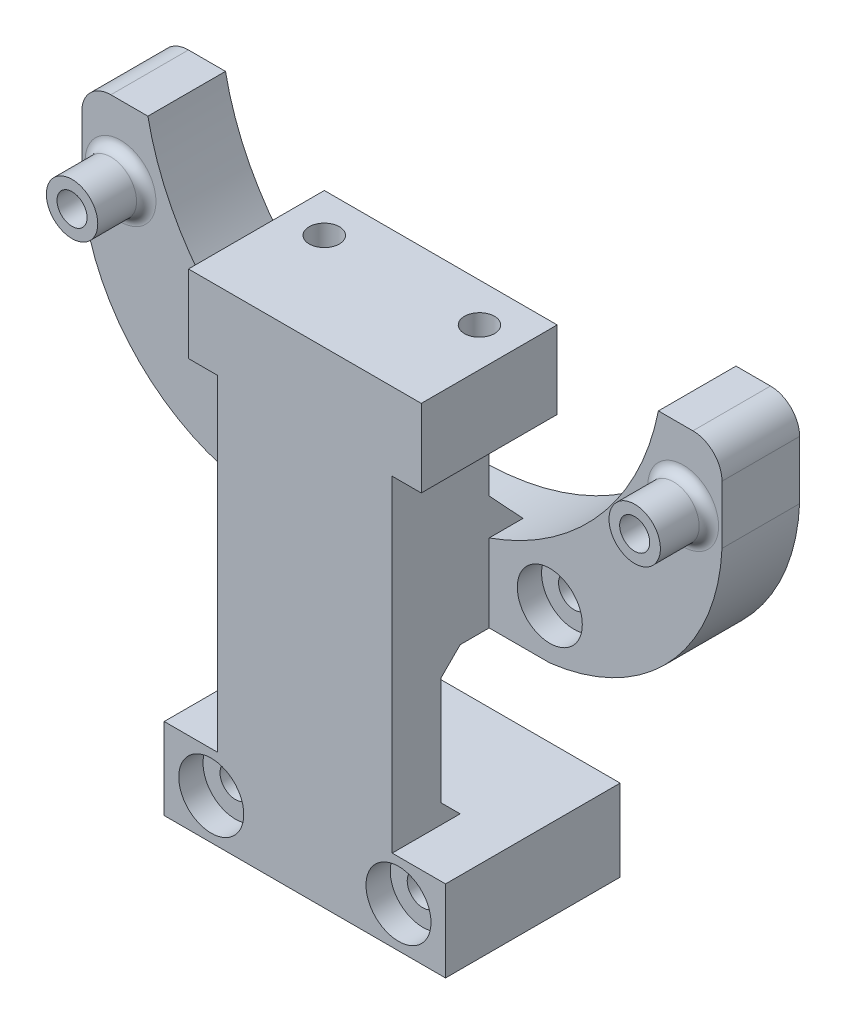
from build123d import *

# Parameters (mm, degrees)
SKETCH_1_R          = 1.6
SKETCH_1_R_2        = 1.55
EXTRUDE_1_DEPTH     = 8
SKETCH_2_R          = 1.6
EXTRUDE_2_DEPTH     = 10
SKETCH_5_R          = 2.65
SKETCH_5_R_2        = 1.55
EXTRUDE_3_DEPTH     = 5
SKETCH_6_R          = 3.35
CUT_EXTRUDE_1_DEPTH = 2.5
SKETCH_13_W         = 29
SKETCH_13_H         = 8
EXTRUDE_6_DEPTH     = 8.4
SKETCH_14_R         = 1.6
CUT_EXTRUDE_4_DEPTH = 19
SKETCH_15_R         = 3.35
CUT_EXTRUDE_5_DEPTH = 2.5
EXTRUDE_7_DEPTH     = 8
SKETCH_20_R         = 1.55
CUT_EXTRUDE_7_DEPTH = 5
CHAMFER_2_SIZE      = 3.5
CHAMFER_3_SIZE      = 1.5
SKETCH_21_W         = 4.98994274
SKETCH_21_H         = 15.1
CUT_EXTRUDE_8_DEPTH = 26
CHAMFER_5_SIZE      = 2
FILLET_1_R          = 1


with BuildPart() as part:
    # 草图1 → 凸台-拉伸1 (new body)
    with BuildSketch(Plane.XY):
        with BuildLine():
            Line((-31.726131322, 22.677257125), (-31.726131322, 16.677257125))
            ThreePointArc((-31.726131322, 16.677257125), (-26.352930604, 3.872967216), (-13.976131322, -2.422742875))
            Line((-13.976131322, -2.422742875), (16.523868678, -2.422742875))
            ThreePointArc((16.523868678, -2.422742875), (28.90066796, 3.872967216), (34.273868678, 16.677257125))
            Line((34.273868678, 16.677257125), (34.273868678, 22.677257125))
            ThreePointArc((34.273868678, 22.677257125), (33.395189022, 24.798577469), (31.273868678, 25.677257125))
            Line((31.273868678, 25.677257125), (27.717127655, 25.677257125))
            ThreePointArc((27.717127655, 25.677257125), (1.404173951, 4.105735727), (-24.908779753, 25.677257125))
            Line((-24.908779753, 25.677257125), (-28.726131322, 25.677257125))
            ThreePointArc((-28.726131322, 25.677257125), (-30.847451665, 24.798577469), (-31.726131322, 22.677257125))
        make_face()
        with Locations((-13.976131322, 2.677257125)):
            Circle(SKETCH_1_R, mode=Mode.SUBTRACT)
        with Locations((16.523868678, 2.677257125)):
            Circle(SKETCH_1_R, mode=Mode.SUBTRACT)
        with Locations((30.273868678, 18.477257125)):
            Circle(SKETCH_1_R_2, mode=Mode.SUBTRACT)
        with Locations((-27.726131322, 18.477257125)):
            Circle(SKETCH_1_R_2, mode=Mode.SUBTRACT)
    extrude(amount=EXTRUDE_1_DEPTH)

    # 草图2 → 凸台-拉伸2 (add)
    with BuildSketch(Plane.XY.offset(8)):
        Polygon((-7.726131322, -17.522742875), (-11.226131322, -17.522742875), (-13.226131322, -17.522742875), (-13.226131322, -25.922742875), (-11.226131322, -25.922742875), (13.773868678, -25.922742875), (15.773868678, -25.922742875), (15.773868678, -17.522742875), (13.773868678, -17.522742875), (10.273868678, -17.522742875), (10.273868678, -2.422742875), (10.273868678, 20.927257125), (10.273868678, 24.127257125), (-7.726131322, 24.127257125), (-7.726131322, 20.927257125), (-7.726131322, -2.422742875), align=None)
        with Locations((10.923868678, -21.722742875)):
            Circle(SKETCH_2_R, mode=Mode.SUBTRACT)
        with Locations((-8.376131322, -21.722742875)):
            Circle(SKETCH_2_R, mode=Mode.SUBTRACT)
    extrude(amount=EXTRUDE_2_DEPTH)

    # 草图4 → 切除-旋转4 (revolve, cut)
    with BuildSketch(Plane(origin=(0, 18.477257125, 0), x_dir=(-1, 0, 0), z_dir=(0, -1, 0))):
        Polygon((-30.273868678, 0), (-33.273868678, 0), (-31.823868678, -2.5), (-30.273868678, -2.5), align=None)
    cut_revolve_4 = revolve(axis=Axis((30.273868678, 18.477257125, 2.5), (0, 0, 1)), mode=Mode.SUBTRACT)

    # 镜向1: 切除-旋转4 across plane
    add(cut_revolve_4.mirror(Plane(origin=(1.273868678, 0, 0), x_dir=(0, 0, 1), z_dir=(1, 0, 0))), mode=Mode.SUBTRACT)

    # 草图5 → 凸台-拉伸3 (add)
    with BuildSketch(Plane.XY.offset(8)):
        with Locations((-27.726131322, 18.477257125)):
            Circle(SKETCH_5_R)
        with Locations((-27.726131322, 18.477257125)):
            Circle(SKETCH_5_R_2, mode=Mode.SUBTRACT)
        with Locations((30.273868678, 18.477257125)):
            Circle(SKETCH_5_R)
        with Locations((30.273868678, 18.477257125)):
            Circle(SKETCH_5_R_2, mode=Mode.SUBTRACT)
    extrude(amount=EXTRUDE_3_DEPTH)

    # 草图6 → 切除-拉伸1 (cut)
    with BuildSketch(Plane.XY.offset(8)):
        with Locations((-13.976131322, 2.677257125)):
            Circle(SKETCH_6_R)
        with Locations((16.523868678, 2.677257125)):
            Circle(SKETCH_6_R)
    extrude(amount=-CUT_EXTRUDE_1_DEPTH, mode=Mode.SUBTRACT)

    # 草图13 → 凸台-拉伸6 (add)
    with BuildSketch(Plane.XZ.offset(25.922742875)):
        with Locations((1.273868678, 4)):
            Rectangle(SKETCH_13_W, SKETCH_13_H)
    extrude(amount=-EXTRUDE_6_DEPTH)

    # 草图14 → 切除-拉伸4 (cut, through all)
    with BuildSketch(Plane(origin=(0, 0, 0), x_dir=(-1, 0, 0), z_dir=(0, 0, -1))):
        with Locations((-10.923868678, -21.722742875)):
            Circle(SKETCH_14_R)
        with Locations((8.376131322, -21.722742875)):
            Circle(SKETCH_14_R)
    extrude(amount=-CUT_EXTRUDE_4_DEPTH, mode=Mode.SUBTRACT)

    # 草图15 → 切除-拉伸5 (cut)
    with BuildSketch(Plane.XY.offset(18)):
        with Locations((-8.376131322, -21.722742875)):
            Circle(SKETCH_15_R)
        with Locations((10.923868678, -21.722742875)):
            Circle(SKETCH_15_R)
    extrude(amount=-CUT_EXTRUDE_5_DEPTH, mode=Mode.SUBTRACT)

    # 草图16 → 凸台-拉伸7 (add)
    with BuildSketch(Plane(origin=(0, 24.127257125, 0), x_dir=(1, 0, 0), z_dir=(0, 1, 0))):
        Polygon((-7.726131322, -18), (-10.726131322, -18), (-10.726131322, -8), (-10.726131322, -3.990704144), (13.273868678, -3.990704144), (13.273868678, -8), (13.273868678, -18), align=None)
    extrude(amount=-EXTRUDE_7_DEPTH)

    # 草图20 → 切除-拉伸7 (cut)
    with BuildSketch(Plane(origin=(0, 24.127257125, 0), x_dir=(1, 0, 0), z_dir=(0, 1, 0))):
        with Locations((-6.726131322, -8)):
            Circle(SKETCH_20_R)
        with Locations((9.273868678, -8)):
            Circle(SKETCH_20_R)
    extrude(amount=-CUT_EXTRUDE_7_DEPTH, mode=Mode.SUBTRACT)

    # 倒角2
    chamfer_2_edges = [part.edges().sort_by_distance(p)[0] for p in [
        (1.265856801, 4.10609221, 8),
    ]]
    chamfer(chamfer_2_edges, length=CHAMFER_2_SIZE)

    # 倒角3
    chamfer_3_edges = [part.edges().sort_by_distance(p)[0] for p in [
        (1.273868678, 16.127257125, 8),
    ]]
    chamfer(chamfer_3_edges, length=CHAMFER_3_SIZE)

    # 草图21 → 切除-拉伸8 (cut)
    with BuildSketch(Plane(origin=(10.273868678, 0, 0), x_dir=(0, 0, -1), z_dir=(1, 0, 0))):
        with Locations((-10.49497137, -9.972742875)):
            Rectangle(SKETCH_21_W, SKETCH_21_H)
    extrude(amount=-CUT_EXTRUDE_8_DEPTH, mode=Mode.SUBTRACT)

    # 倒角5
    chamfer_5_edges = [part.edges().sort_by_distance(p)[0] for p in [
        (1.273868678, -17.522742875, 12.98994274),
        (1.273868678, -2.422742875, 12.98994274),
    ]]
    chamfer(chamfer_5_edges, length=CHAMFER_5_SIZE)

    # 圆角1
    fillet_1_edges = [part.edges().sort_by_distance(p)[0] for p in [
        (-30.376131322, 18.477257125, 8),
        (27.623868678, 18.477257125, 8),
    ]]
    fillet(fillet_1_edges, radius=FILLET_1_R)


solid = part.part
